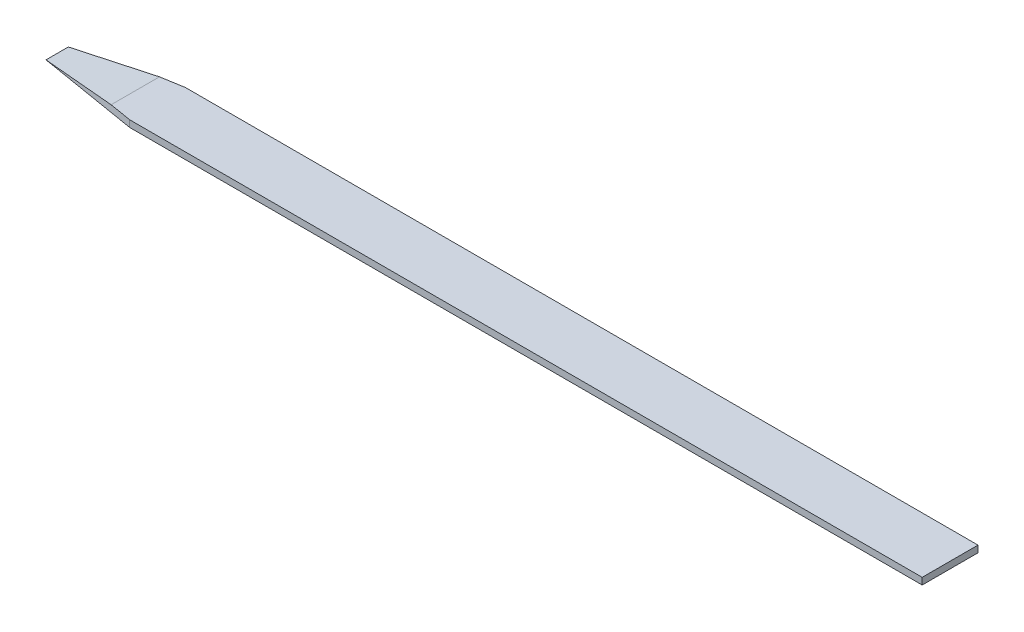
from build123d import *

# Parameters (mm, degrees)
BOSS_EXTRUDE1_DEPTH = 0.06
CUT_EXTRUDE3_DEPTH  = 9.09728967
CUT_EXTRUDE4_DEPTH  = 9.09728967
CUT_EXTRUDE5_DEPTH  = 2.5


with BuildPart() as part:
    # Sketch1 → Boss-Extrude1 (new body)
    with BuildSketch(Plane(origin=(0, 0, 0), x_dir=(1, 0, 0), z_dir=(0, 1, 0))):
        with BuildLine():
            ThreePointArc((-0.362264151, -0.932075472), (-0.747576714, -0.664175471), (-0.968245837, -0.25))
            Line((-0.968245837, -0.25), (-4, -0.25))
            Line((-4, -0.25), (-0.362264151, -0.932075472))
        make_face()
        with BuildLine():
            ThreePointArc((-0.968245837, 0.25), (-0.747576714, 0.664175471), (-0.362264151, 0.932075472))
            Line((-0.362264151, 0.932075472), (-4, 0.25))
            Line((-4, 0.25), (-0.968245837, 0.25))
        make_face()
        with BuildLine():
            ThreePointArc((-0.968245837, -0.25), (-1, 0), (-0.968245837, 0.25))
            Line((-0.968245837, 0.25), (-4, 0.25))
            Line((-4, 0.25), (-8, 0.25))
            Line((-8, 0.25), (-8, -0.25))
            Line((-8, -0.25), (-4, -0.25))
            Line((-4, -0.25), (-0.968245837, -0.25))
        make_face()
        with BuildLine():
            Line((0, -1), (0, -0.25))
            Line((0, -0.25), (-0.968245837, -0.25))
            ThreePointArc((-0.968245837, -0.25), (-0.747576714, -0.664175471), (-0.362264151, -0.932075472))
            Line((-0.362264151, -0.932075472), (0, -1))
        make_face()
        with BuildLine():
            Line((0, 0.25), (0, 1))
            Line((0, 1), (-0.362264151, 0.932075472))
            ThreePointArc((-0.362264151, 0.932075472), (-0.747576714, 0.664175471), (-0.968245837, 0.25))
            Line((-0.968245837, 0.25), (0, 0.25))
        make_face()
        with BuildLine():
            Line((0, -0.25), (0, 0.25))
            Line((0, 0.25), (-0.968245837, 0.25))
            ThreePointArc((-0.968245837, 0.25), (-1, 0), (-0.968245837, -0.25))
            Line((-0.968245837, -0.25), (0, -0.25))
        make_face()
    extrude(amount=BOSS_EXTRUDE1_DEPTH)

    # Sketch5 → Cut-Extrude3 (cut, through all)
    with BuildSketch(Plane.XY.offset(0.25)):
        Polygon((-8, 0), (-8, 0.06), (-7.3, 0.06), align=None)
    extrude(amount=-CUT_EXTRUDE3_DEPTH, mode=Mode.SUBTRACT)

    # 3DSketch1 → Cut-Extrude4 (cut, through all)
    with BuildSketch(Plane(origin=(-8, 0.06, 0.25), x_dir=(0.8741572761215383, 0, -0.4856429311786313), z_dir=(0, -1, 0))):
        Polygon((0, 0), (0.07284644, -0.131123591), (0.786741549, 0.437078638), align=None)
        Polygon((1.029563014, 0), (0.242821466, -0.437078638), (0.169975026, -0.305955047), align=None)
    extrude(amount=CUT_EXTRUDE4_DEPTH, mode=Mode.SUBTRACT)

    # Sketch6 → Cut-Extrude5 (cut)
    with BuildSketch(Plane(origin=(0, 0.06, 0), x_dir=(1, 0, 0), z_dir=(0, 1, 0))):
        Polygon((0, 1), (-4, 0.25), (0, 0.25), align=None)
        Polygon((0, -0.25), (-4, -0.25), (0, -1), align=None)
    extrude(amount=-CUT_EXTRUDE5_DEPTH, mode=Mode.SUBTRACT)


solid = part.part
